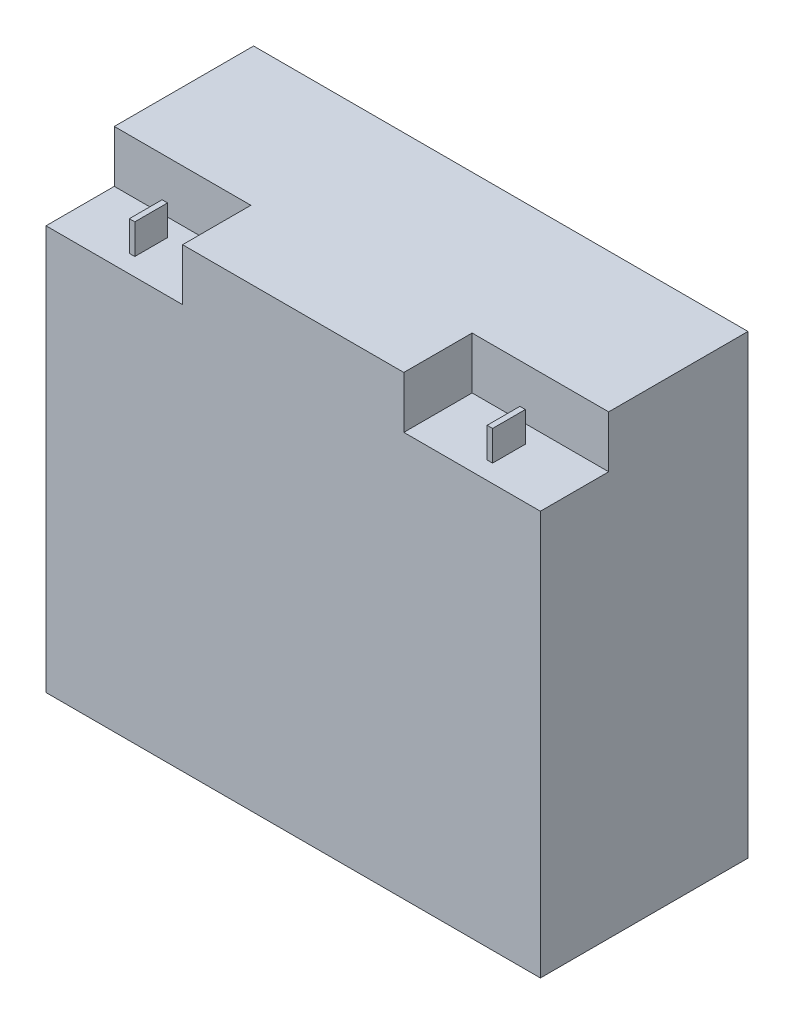
from build123d import *

# Parameters (mm, degrees)
SKETCH1_W           = 181
SKETCH1_H           = 167
BOSS_EXTRUDE1_DEPTH = 38
SKETCH3_W           = 50
SKETCH3_H           = 19
CUT_EXTRUDE1_DEPTH  = 25
SKETCH4_W           = 2
SKETCH4_H           = 12
BOSS_EXTRUDE2_DEPTH = 11


with BuildPart() as part:
    # Sketch1 → Boss-Extrude1 (new body, symmetric)
    with BuildSketch(Plane.XY):
        Rectangle(SKETCH1_W, SKETCH1_H)
    extrude(amount=BOSS_EXTRUDE1_DEPTH, both=True)

    # Sketch3 → Cut-Extrude1 (cut)
    with BuildSketch(Plane.XY.offset(38)):
        with Locations((-65.5, 74)):
            Rectangle(SKETCH3_W, SKETCH3_H)
        with Locations((65.5, 74)):
            Rectangle(SKETCH3_W, SKETCH3_H)
    extrude(amount=-CUT_EXTRUDE1_DEPTH, mode=Mode.SUBTRACT)

    # Sketch4 → Boss-Extrude2 (add)
    with BuildSketch(Plane(origin=(0, 64.5, 0), x_dir=(1, 0, 0), z_dir=(0, 1, 0))):
        with Locations((-65.5, -25.5)):
            Rectangle(SKETCH4_W, SKETCH4_H)
        with Locations((65.5, -25.5)):
            Rectangle(SKETCH4_W, SKETCH4_H)
    extrude(amount=BOSS_EXTRUDE2_DEPTH)


solid = part.part
